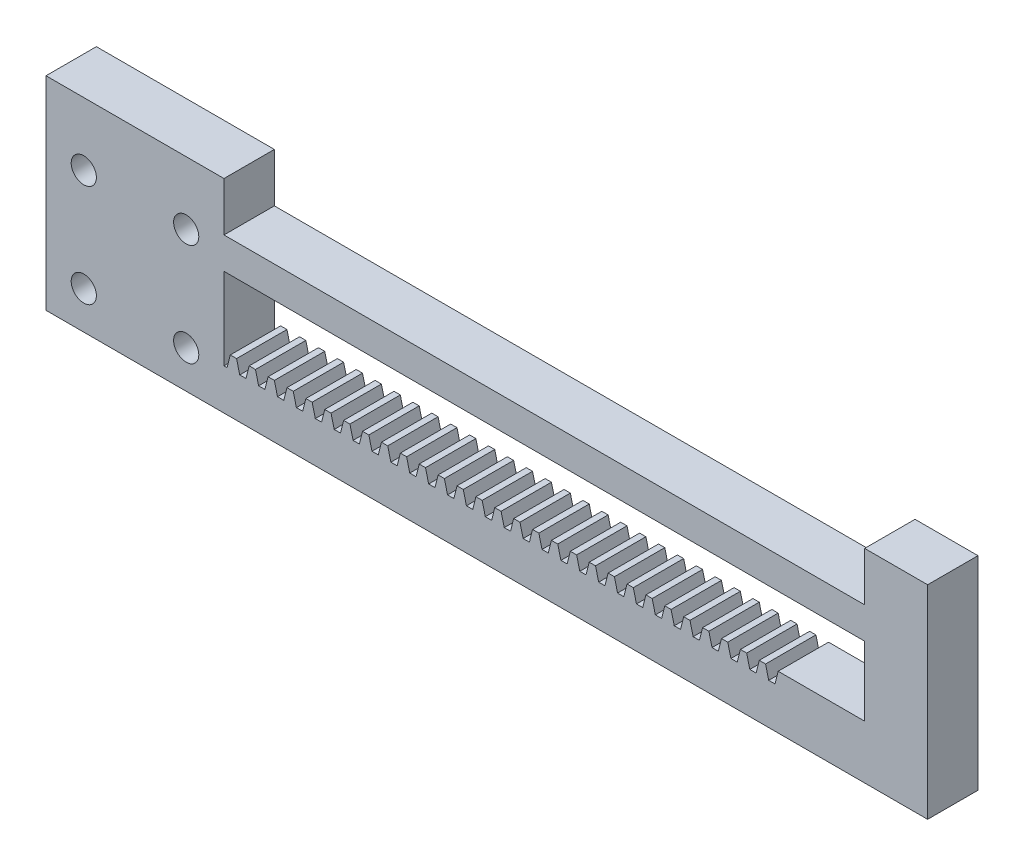
from build123d import *

# Parameters (mm, degrees)
SKETCH1_R           = 2
BOSS_EXTRUDE1_DEPTH = 8


with BuildPart() as part:
    # Sketch1 → Boss-Extrude1 (new body)
    with BuildSketch(Plane.XY):
        Polygon((-111.736544033, -14.131727984), (-9.968599743, -14.131727984), (0, -14.131727984), (0, 18.131727984), (-10, 18.131727984), (-10, 10.368272016), (-111.736544033, 10.368272016), (-111.736544033, 18.131727984), (-140, 18.131727984), (-140, -14.131727984), align=None)
        with Locations((-134, 8.131727984)):
            Circle(SKETCH1_R, mode=Mode.SUBTRACT)
        with Locations((-117.736544033, 8.131727984)):
            Circle(SKETCH1_R, mode=Mode.SUBTRACT)
        with Locations((-134, -8.131727984)):
            Circle(SKETCH1_R, mode=Mode.SUBTRACT)
        with Locations((-117.736544033, -8.131727984)):
            Circle(SKETCH1_R, mode=Mode.SUBTRACT)
        Polygon((-111.736544033, -7.631727984), (-111.736544033, 5.368272016), (-10, 5.368272016), (-10, -5.631727984), (-23.736544033, -5.631727984), (-24.236544033, -7.631727984), (-24.736544033, -7.631727984), (-25.236544033, -7.631727984), (-25.736544033, -5.631727984), (-26.736544033, -5.631727984), (-27.236544033, -7.631727984), (-27.736544033, -7.631727984), (-28.236544033, -7.631727984), (-28.736544033, -5.631727984), (-29.736544033, -5.631727984), (-30.236544033, -7.631727984), (-30.736544033, -7.631727984), (-31.236544033, -7.631727984), (-31.736544033, -5.631727984), (-32.736544033, -5.631727984), (-33.236544033, -7.631727984), (-33.736544033, -7.631727984), (-34.236544033, -7.631727984), (-34.736544033, -5.631727984), (-35.736544033, -5.631727984), (-36.236544033, -7.631727984), (-36.736544033, -7.631727984), (-37.236544033, -7.631727984), (-37.736544033, -5.631727984), (-38.736544033, -5.631727984), (-39.236544033, -7.631727984), (-39.736544033, -7.631727984), (-40.236544033, -7.631727984), (-40.736544033, -5.631727984), (-41.736544033, -5.631727984), (-42.236544033, -7.631727984), (-42.736544033, -7.631727984), (-43.236544033, -7.631727984), (-43.736544033, -5.631727984), (-44.736544033, -5.631727984), (-45.236544033, -7.631727984), (-45.736544033, -7.631727984), (-46.236544033, -7.631727984), (-46.736544033, -5.631727984), (-47.736544033, -5.631727984), (-48.236544033, -7.631727984), (-48.736544033, -7.631727984), (-49.236544033, -7.631727984), (-49.736544033, -5.631727984), (-50.736544033, -5.631727984), (-51.236544033, -7.631727984), (-51.736544033, -7.631727984), (-52.236544033, -7.631727984), (-52.736544033, -5.631727984), (-53.736544033, -5.631727984), (-54.236544033, -7.631727984), (-54.736544033, -7.631727984), (-55.236544033, -7.631727984), (-55.736544033, -5.631727984), (-56.736544033, -5.631727984), (-57.236544033, -7.631727984), (-57.736544033, -7.631727984), (-58.236544033, -7.631727984), (-58.736544033, -5.631727984), (-59.736544033, -5.631727984), (-60.236544033, -7.631727984), (-60.736544033, -7.631727984), (-61.236544033, -7.631727984), (-61.736544033, -5.631727984), (-62.736544033, -5.631727984), (-63.236544033, -7.631727984), (-63.736544033, -7.631727984), (-64.236544033, -7.631727984), (-64.736544033, -5.631727984), (-65.736544033, -5.631727984), (-66.236544033, -7.631727984), (-66.736544033, -7.631727984), (-67.236544033, -7.631727984), (-67.736544033, -5.631727984), (-68.736544033, -5.631727984), (-69.236544033, -7.631727984), (-69.736544033, -7.631727984), (-70.236544033, -7.631727984), (-70.736544033, -5.631727984), (-71.736544033, -5.631727984), (-72.236544033, -7.631727984), (-72.736544033, -7.631727984), (-73.236544033, -7.631727984), (-73.736544033, -5.631727984), (-74.736544033, -5.631727984), (-75.236544033, -7.631727984), (-75.736544033, -7.631727984), (-76.236544033, -7.631727984), (-76.736544033, -5.631727984), (-77.736544033, -5.631727984), (-78.236544033, -7.631727984), (-78.736544033, -7.631727984), (-79.236544033, -7.631727984), (-79.736544033, -5.631727984), (-80.736544033, -5.631727984), (-81.236544033, -7.631727984), (-81.736544033, -7.631727984), (-82.236544033, -7.631727984), (-82.736544033, -5.631727984), (-83.736544033, -5.631727984), (-84.236544033, -7.631727984), (-84.736544033, -7.631727984), (-85.236544033, -7.631727984), (-85.736544033, -5.631727984), (-86.736544033, -5.631727984), (-87.236544033, -7.631727984), (-87.736544033, -7.631727984), (-88.236544033, -7.631727984), (-88.736544033, -5.631727984), (-89.736544033, -5.631727984), (-90.236544033, -7.631727984), (-90.736544033, -7.631727984), (-91.236544033, -7.631727984), (-91.736544033, -5.631727984), (-92.736544033, -5.631727984), (-93.236544033, -7.631727984), (-93.736544033, -7.631727984), (-94.236544033, -7.631727984), (-94.736544033, -5.631727984), (-95.736544033, -5.631727984), (-96.236544033, -7.631727984), (-96.736544033, -7.631727984), (-97.236544033, -7.631727984), (-97.736544033, -5.631727984), (-98.736544033, -5.631727984), (-99.236544033, -7.631727984), (-99.736544033, -7.631727984), (-100.236544033, -7.631727984), (-100.736544033, -5.631727984), (-101.736544033, -5.631727984), (-102.236544033, -7.631727984), (-102.736544033, -7.631727984), (-103.236544033, -7.631727984), (-103.736544033, -5.631727984), (-104.736544033, -5.631727984), (-105.236544033, -7.631727984), (-105.736544033, -7.631727984), (-106.236544033, -7.631727984), (-106.736544033, -5.631727984), (-107.736544033, -5.631727984), (-108.236544033, -7.631727984), (-108.736544033, -7.631727984), (-109.236544033, -7.631727984), (-109.736544033, -5.631727984), (-110.736544033, -5.631727984), (-111.236544033, -7.631727984), align=None, mode=Mode.SUBTRACT)
    extrude(amount=BOSS_EXTRUDE1_DEPTH)


solid = part.part
